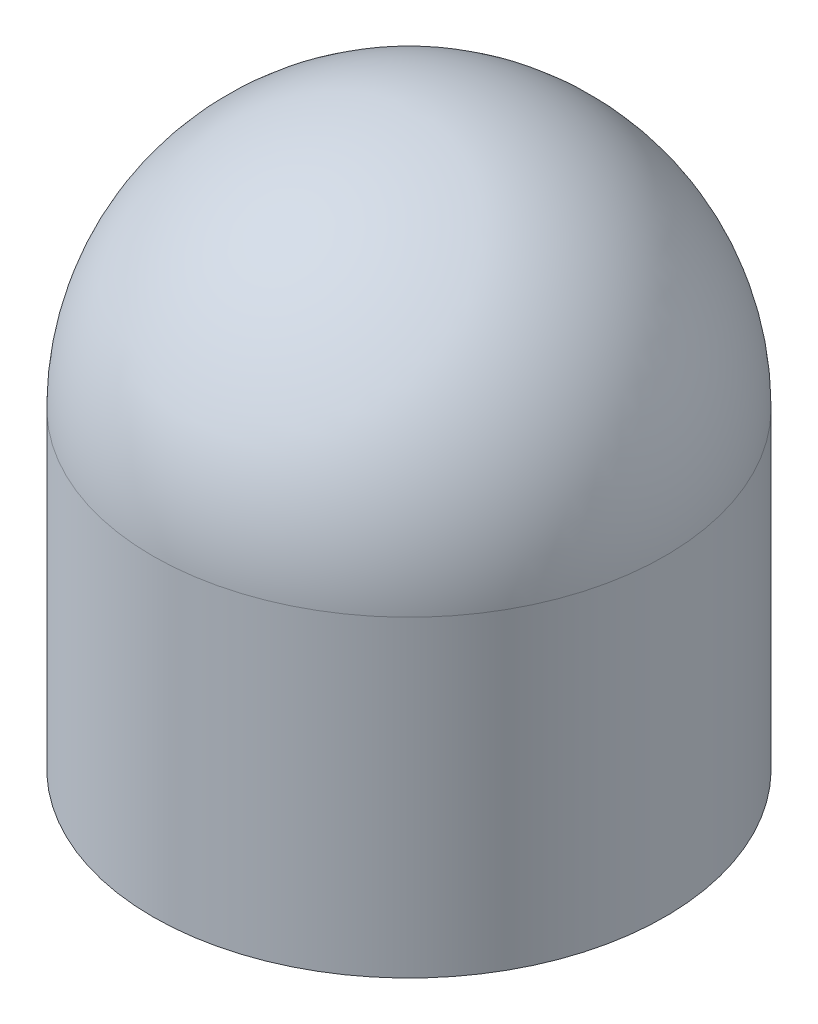
from build123d import *

# Parameters (mm, degrees)
SKETCH1_R           = 5
BOSS_EXTRUDE1_DEPTH = 6.1
REVOLVE1_ANGLE      = 360


with BuildPart() as part:
    # Sketch1 → Boss-Extrude1 (new body)
    with BuildSketch(Plane(origin=(0, 0, 0), x_dir=(1, 0, 0), z_dir=(0, 1, 0))):
        Circle(SKETCH1_R)
    extrude(amount=BOSS_EXTRUDE1_DEPTH)

    # Sketch2 → Revolve1 (revolve, symmetric)
    with BuildSketch(Plane(origin=(0, 6.1, 0), x_dir=(1, 0, 0), z_dir=(0, 1, 0))) as revolve1_sk:
        with BuildLine():
            Line((0, 5), (0, -5))
            ThreePointArc((0, -5), (-5, 0), (0, 5))
        make_face()
    revolve(axis=Axis((0, 6.1, -5), (0, 0, 1)), revolution_arc=REVOLVE1_ANGLE / 2)
    revolve(revolve1_sk.sketch, axis=Axis((0, 6.1, -5), (0, 0, -1)), revolution_arc=REVOLVE1_ANGLE / 2)


solid = part.part
